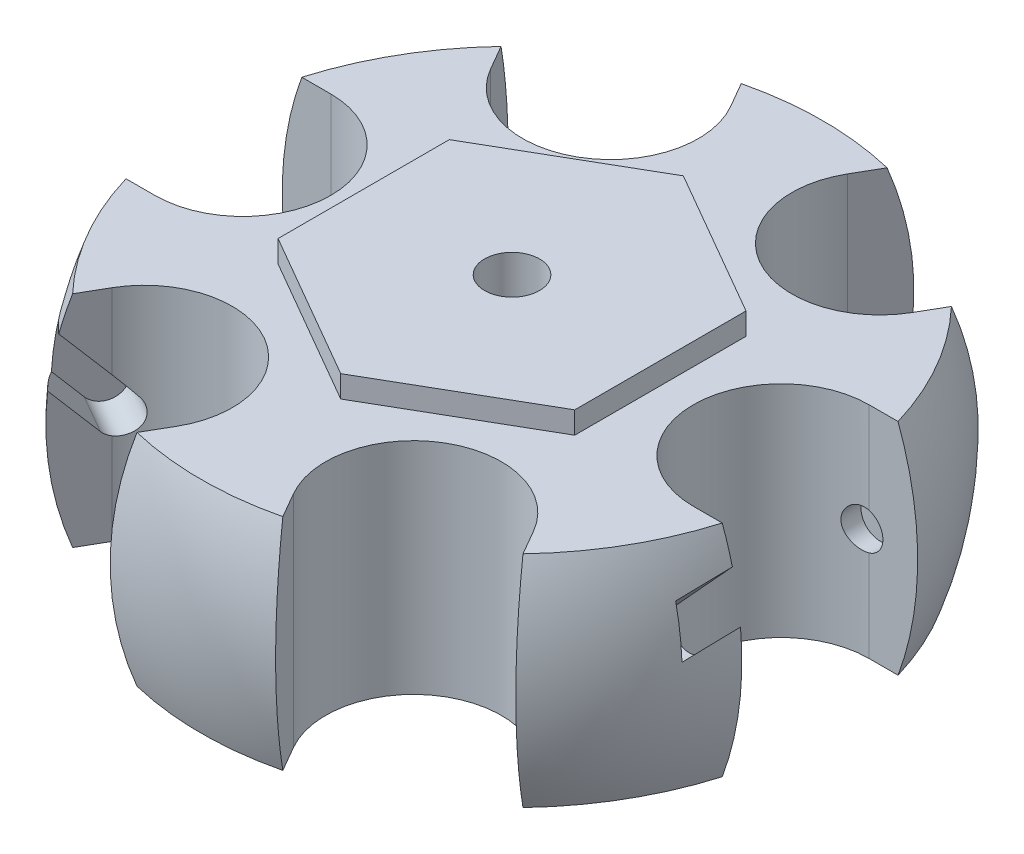
from build123d import *

# Parameters (mm, degrees)
SKETCH2_W           = 136.932578545
SKETCH2_H           = 134.741657288
CUT_EXTRUDE1_DEPTH  = 41
SKETCH3_W           = 157.433341732
SKETCH3_H           = 136.306601043
CUT_EXTRUDE2_DEPTH  = 41
CUT_EXTRUDE3_DEPTH  = 41
CUT_EXTRUDE4_START  = -3
SKETCH8_R           = 3.5
CUT_EXTRUDE4_DEPTH  = 43
CUT_EXTRUDE5_DEPTH  = 24
CIRPATTERN1_COUNT   = 6
CIRPATTERN2_COUNT   = 3
BOSS_EXTRUDE1_DEPTH = 4
CUT_EXTRUDE6_DEPTH  = 5
SKETCH12_R          = 5
CUT_EXTRUDE7_DEPTH  = 45.0000001


with BuildPart() as part:
    # Sketch1 → Revolve1 (revolve)
    with BuildSketch(Plane.XY):
        with BuildLine():
            Line((0, 0), (0, 60))
            ThreePointArc((0, 60), (-60, 0), (0, -60))
            Line((0, -60), (0, 0))
        make_face()
    revolve(axis=Axis((0, 0, 0), (0, 1, 0)))

    # Sketch2 → Cut-Extrude1 (cut, through all)
    with BuildSketch(Plane(origin=(0, 20, 0), x_dir=(1, 0, 0), z_dir=(0, 1, 0))):
        with Locations((2.269168444, -1.72143813)):
            Rectangle(SKETCH2_W, SKETCH2_H)
    extrude(amount=CUT_EXTRUDE1_DEPTH, mode=Mode.SUBTRACT)

    # Sketch3 → Cut-Extrude2 (cut, through all)
    with BuildSketch(Plane(origin=(0, -20, 0), x_dir=(1, 0, 0), z_dir=(0, 1, 0))):
        with Locations((3.912359387, -2.503910008)):
            Rectangle(SKETCH3_W, SKETCH3_H)
    extrude(amount=-CUT_EXTRUDE2_DEPTH, mode=Mode.SUBTRACT)

    # Sketch7 → Cut-Extrude3 (cut, through all)
    with BuildSketch(Plane(origin=(0, 20, 0), x_dir=(1, 0, 0), z_dir=(0, 1, 0))):
        with BuildLine():
            Line((48.989794856, 16), (63.030663811, 16))
            Line((63.030663811, 16), (63.030663811, -16))
            Line((63.030663811, -16), (48.989794856, -16))
            ThreePointArc((48.989794856, -16), (32.989794856, 0), (48.989794856, 16))
        make_face()
    cut_extrude3 = extrude(amount=-CUT_EXTRUDE3_DEPTH, mode=Mode.SUBTRACT)

    # Sketch8 → Cut-Extrude4 (cut)
    with BuildSketch(Plane.XY.offset(-16).offset(CUT_EXTRUDE4_START)):
        with Locations((48, 0)):
            Circle(SKETCH8_R)
    cut_extrude4 = extrude(amount=CUT_EXTRUDE4_DEPTH, mode=Mode.SUBTRACT)

    # Sketch9 → Cut-Extrude5 (cut)
    with BuildSketch(Plane.XY):
        with BuildLine():
            Line((45.422340515, 2.36762995), (57.946221285, 16.002488752))
            Line((57.946221285, 16.002488752), (63.101540255, 11.267228853))
            Line((63.101540255, 11.267228853), (50.577659485, -2.36762995))
            ThreePointArc((50.577659485, -2.36762995), (45.63237005, -2.577659485), (45.422340515, 2.36762995))
        make_face()
    cut_extrude5 = extrude(amount=CUT_EXTRUDE5_DEPTH, mode=Mode.SUBTRACT)

    # CirPattern1: Cut-Extrude3 ×6 about axis
    cirpattern1_axis = Axis((0, 0, 0), (0, 1, 0))
    for i in range(1, CIRPATTERN1_COUNT):
        add(cut_extrude3.rotate(cirpattern1_axis, i * 360 / CIRPATTERN1_COUNT), mode=Mode.SUBTRACT)

    # CirPattern2: Cut-Extrude4, Cut-Extrude5 ×3 about axis
    cirpattern2_axis = Axis((0, 0, 0), (0, 1, 0))
    for i in range(1, CIRPATTERN2_COUNT):
        add(cut_extrude4.rotate(cirpattern2_axis, i * 360 / CIRPATTERN2_COUNT), mode=Mode.SUBTRACT)
        add(cut_extrude5.rotate(cirpattern2_axis, i * 360 / CIRPATTERN2_COUNT), mode=Mode.SUBTRACT)

    # Sketch10 → Boss-Extrude1 (add)
    with BuildSketch(Plane(origin=(0, 20, 0), x_dir=(1, 0, 0), z_dir=(0, 1, 0))):
        Polygon((27, -15.588457268), (27, 15.588457268), (0, 31.176914536), (-27, 15.588457268), (-27, -15.588457268), (0, -31.176914536), align=None)
    extrude(amount=BOSS_EXTRUDE1_DEPTH)

    # Sketch11 → Cut-Extrude6 (cut)
    with BuildSketch(Plane.XZ.offset(20)):
        Polygon((27, -15.588457268), (27, 15.588457268), (0, 31.176914536), (-27, 15.588457268), (-27, -15.588457268), (0, -31.176914536), align=None)
    extrude(amount=-CUT_EXTRUDE6_DEPTH, mode=Mode.SUBTRACT)

    # Sketch12 → Cut-Extrude7 (cut, through all)
    with BuildSketch(Plane(origin=(0, 24, 0), x_dir=(1, 0, 0), z_dir=(0, 1, 0))):
        Circle(SKETCH12_R)
    extrude(amount=-CUT_EXTRUDE7_DEPTH, mode=Mode.SUBTRACT)


solid = part.part
